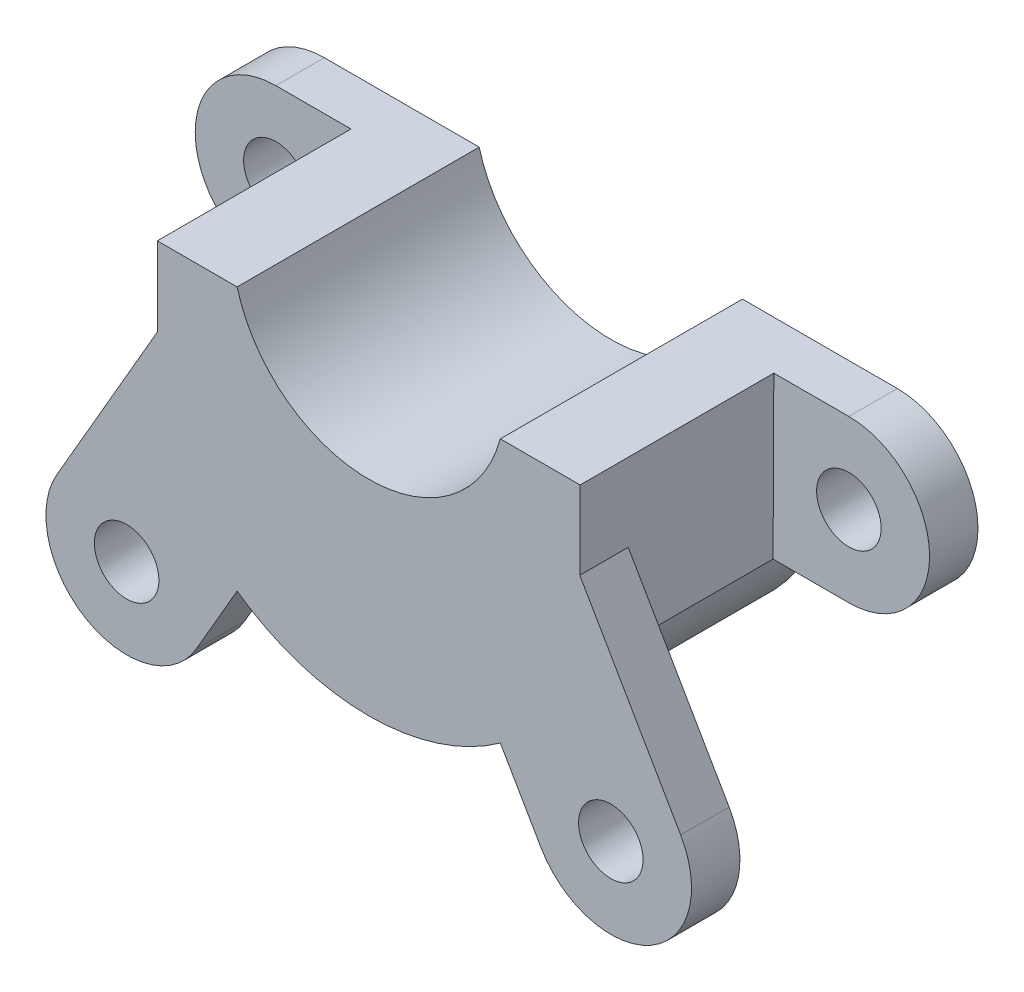
from build123d import *

# Parameters (mm, degrees)
ESBO_O1_R                = 2
RESSALTO_EXTRUS_O1_DEPTH = 3
RESSALTO_EXTRUS_O2_DEPTH = 12
ESBO_O3_R                = 2
RESSALTO_EXTRUS_O3_DEPTH = 3


with BuildPart() as part:
    # Esboço1 → Ressalto-extrusão1 (new body)
    with BuildSketch(Plane.XY):
        with BuildLine():
            Line((-17.75, 4.940964043), (-13.099117311, 4.940964043))
            Line((-13.099117311, 4.940964043), (-8.154782397, 4.940964043))
            ThreePointArc((-8.154782397, 4.940964043), (0, -1.302389684), (8.154782397, 4.940964043))
            Line((8.154782397, 4.940964043), (13.099117311, 4.940964043))
            Line((13.099117311, 4.940964043), (17.75, 4.940964043))
            ThreePointArc((17.75, 4.940964043), (22.75, -0.059035957), (17.75, -5.059035957))
            Line((17.75, -5.059035957), (13.053970859, -5.059035957))
            ThreePointArc((13.053970859, -5.059035957), (0, -14), (-13.053970859, -5.059035957))
            Line((-13.053970859, -5.059035957), (-17.75, -5.059035957))
            ThreePointArc((-17.75, -5.059035957), (-22.75, -0.059035957), (-17.75, 4.940964043))
        make_face()
        with Locations((-17.75, -0.059035957)):
            Circle(ESBO_O1_R, mode=Mode.SUBTRACT)
        with Locations((17.75, -0.059035957)):
            Circle(ESBO_O1_R, mode=Mode.SUBTRACT)
    extrude(amount=RESSALTO_EXTRUS_O1_DEPTH)

    # Esboço2 → Ressalto-extrusão2 (add)
    with BuildSketch(Plane.XY.offset(3)):
        with BuildLine():
            Line((13.099117311, 4.940964043), (13.053970859, -5.059035957))
            ThreePointArc((13.053970859, -5.059035957), (0, -14), (-13.053970859, -5.059035957))
            Line((-13.053970859, -5.059035957), (-13.099117311, 4.940964043))
            Line((-13.099117311, 4.940964043), (-8.154782397, 4.940964043))
            ThreePointArc((-8.154782397, 4.940964043), (0, -1.302389684), (8.154782397, 4.940964043))
            Line((8.154782397, 4.940964043), (13.099117311, 4.940964043))
        make_face()
    extrude(amount=RESSALTO_EXTRUS_O2_DEPTH)

    # Esboço3 → Ressalto-extrusão3 (add)
    with BuildSketch(Plane.XY.offset(15)):
        with BuildLine():
            Line((13.077187708, 0.083527365), (8.154782397, -11.379785765))
            Line((8.154782397, -11.379785765), (10.671688275, -15.731898104))
            ThreePointArc((10.671688275, -15.731898104), (17.503141549, -17.55706828), (19.328311725, -10.725615007))
            Line((19.328311725, -10.725615007), (13.077187708, 0.083527365))
        make_face()
        with Locations((15, -13.228756555)):
            Circle(ESBO_O3_R, mode=Mode.SUBTRACT)
        with BuildLine():
            Line((-10.671688275, -15.731898104), (-8.154782397, -11.379785765))
            Line((-8.154782397, -11.379785765), (-13.077187708, 0.083527365))
            Line((-13.077187708, 0.083527365), (-19.328311725, -10.725615007))
            ThreePointArc((-19.328311725, -10.725615007), (-17.503141549, -17.55706828), (-10.671688275, -15.731898104))
        make_face()
        with Locations((-15, -13.228756555)):
            Circle(ESBO_O3_R, mode=Mode.SUBTRACT)
    extrude(amount=-RESSALTO_EXTRUS_O3_DEPTH)


solid = part.part
